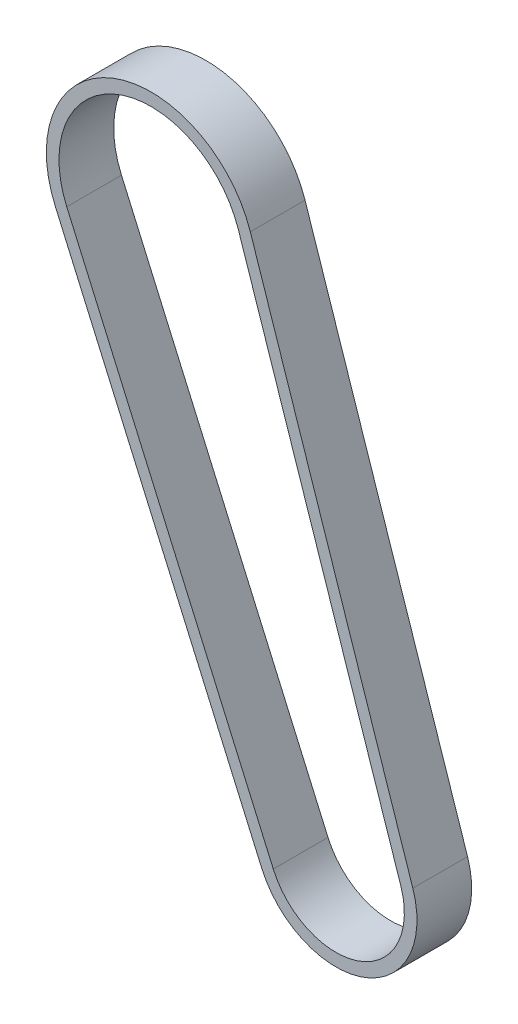
from build123d import *

# Parameters (mm, degrees)
EXTRUDE_THIN1_DEPTH = 11


with BuildPart() as part:
    # Sketch2 → Extrude-Thin1 (new body)
    with BuildSketch(Plane.XY):
        with BuildLine():
            Line((23.943080626, -107.52880284), (-17.57014843, -13.004643105))
            ThreePointArc((-17.57014843, -13.004643105), (-5.873118308, 15.087926542), (21.652778853, 2.113414277))
            Line((21.652778853, 2.113414277), (54.320342986, -95.820212296))
            ThreePointArc((54.320342986, -95.820212296), (44.723114629, -116.181079464), (23.943080626, -107.52880284))
        make_face()
        with BuildLine():
            Line((26.268682256, -106.507442444), (-15.244546799, -11.98328271))
            ThreePointArc((-15.244546799, -11.98328271), (-4.959610618, 12.717883567), (19.243293254, 1.309685996))
            Line((19.243293254, 1.309685996), (51.910857388, -96.623940577))
            ThreePointArc((51.910857388, -96.623940577), (43.809606939, -113.811036489), (26.268682256, -106.507442444))
        make_face(mode=Mode.SUBTRACT)
    extrude(amount=EXTRUDE_THIN1_DEPTH)


solid = part.part
